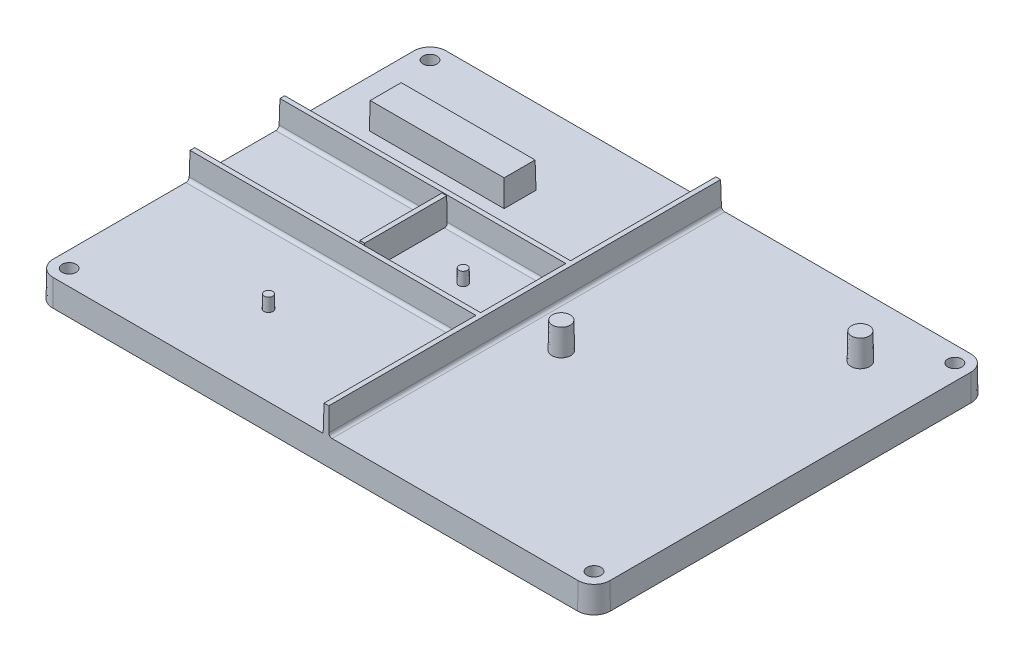
from build123d import *

# Parameters (mm, degrees)
SKETCH1_W            = 170
SKETCH1_H            = 120
BOSS_EXTRUDE1_DEPTH  = 8
SKETCH2_W            = 41.380626675
SKETCH2_H            = 10
BOSS_EXTRUDE2_DEPTH  = 8
SKETCH3_R            = 2
CUT_EXTRUDE1_DEPTH   = 8
SKETCH7_R            = 3
BOSS_EXTRUDE3_DEPTH  = 8
SKETCH8_R            = 1.5
BOSS_EXTRUDE6_DEPTH  = 4
SKETCH9_R            = 1.5
BOSS_EXTRUDE7_DEPTH  = 4
SKETCH10_R           = 3
BOSS_EXTRUDE8_DEPTH  = 8
SKETCH11_W           = 2
SKETCH11_H           = 120
BOSS_EXTRUDE9_DEPTH  = 8
SKETCH13_W           = 87.148503305
SKETCH13_H           = 2
BOSS_EXTRUDE10_DEPTH = 8
BOSS_EXTRUDE11_START = -1.289738394
SKETCH7_3_R          = 3
BOSS_EXTRUDE11_DEPTH = 1.289738394
SKETCH14_W           = 2
SKETCH14_H           = 25
BOSS_EXTRUDE13_DEPTH = 8
SKETCH18_W           = 87.148503305
SKETCH18_H           = 2
BOSS_EXTRUDE16_DEPTH = 8
SKETCH19_R           = 1.5
BOSS_EXTRUDE17_DEPTH = 4
DRAFT3_ANGLE         = 1
FILLET1_R            = 1
FILLET6_R            = 5
DRAFT1_ANGLE         = -1
DRAFT2_ANGLE         = 1
DRAFT4_ANGLE         = 1


with BuildPart() as part:
    # Sketch1 → Boss-Extrude1 (new body)
    with BuildSketch(Plane(origin=(0, 0, 0), x_dir=(1, 0, 0), z_dir=(0, 1, 0))):
        Rectangle(SKETCH1_W, SKETCH1_H)
    extrude(amount=BOSS_EXTRUDE1_DEPTH)

    # Sketch2 → Boss-Extrude2 (add)
    with BuildSketch(Plane(origin=(-17.791513114, 8, -3.068036611), x_dir=(1, 0, 0), z_dir=(0, 1, 0))):
        with Locations((-32.208486886, 28.840032215)):
            Rectangle(SKETCH2_W, SKETCH2_H)
    extrude(amount=BOSS_EXTRUDE2_DEPTH)

    # Sketch3 → Cut-Extrude1 (cut)
    with BuildSketch(Plane(origin=(0, 8, 0), x_dir=(1, 0, 0), z_dir=(0, 1, 0))):
        with Locations((-80, 55)):
            Circle(SKETCH3_R)
        with Locations((-80, -55)):
            Circle(SKETCH3_R)
        with Locations((80, 55)):
            Circle(SKETCH3_R)
        with Locations((80, -55)):
            Circle(SKETCH3_R)
    extrude(amount=-CUT_EXTRUDE1_DEPTH, mode=Mode.SUBTRACT)

    # Sketch7 → Boss-Extrude3 (add)
    with BuildSketch(Plane(origin=(12.703147983, 8, 3.565766466), x_dir=(1, 0, 0), z_dir=(0, 1, 0))):
        with Locations((52.400485428, 44.659504627)):
            Circle(SKETCH7_R)
    extrude(amount=BOSS_EXTRUDE3_DEPTH)

    # Sketch8 → Boss-Extrude6 (add)
    with BuildSketch(Plane(origin=(0, 16, 3.565766466), x_dir=(1, 0, 0), z_dir=(0, 1, 0))):
        with Locations((65.103633411, 44.659504627)):
            Circle(SKETCH8_R)
    extrude(amount=-BOSS_EXTRUDE6_DEPTH)

    # Sketch9 → Boss-Extrude7 (add)
    with BuildSketch(Plane(origin=(0, 16, 3.565766466), x_dir=(1, 0, 0), z_dir=(0, 1, 0))):
        with Locations((64.905146724, 44.273718651)):
            Circle(SKETCH9_R)
    extrude(amount=-BOSS_EXTRUDE7_DEPTH)

    # Sketch10 → Boss-Extrude8 (add)
    with BuildSketch(Plane(origin=(-8.754663217, 8, 20.46794397), x_dir=(1, 0, 0), z_dir=(0, 1, 0))):
        with Locations((25.406295965, 18.856235287)):
            Circle(SKETCH10_R)
    extrude(amount=BOSS_EXTRUDE8_DEPTH)

    # Sketch11 → Boss-Extrude9 (add)
    with BuildSketch(Plane(origin=(4.148503305, 8, 0), x_dir=(1, 0, 0), z_dir=(0, 1, 0))):
        with Locations((-1, 0)):
            Rectangle(SKETCH11_W, SKETCH11_H)
    extrude(amount=BOSS_EXTRUDE9_DEPTH)

    # Sketch13 → Boss-Extrude10 (add)
    with BuildSketch(Plane(origin=(0, 8, 0), x_dir=(1, 0, 0), z_dir=(0, 1, 0))):
        with Locations((-41.425748347, 14.695581419)):
            Rectangle(SKETCH13_W, SKETCH13_H)
    extrude(amount=BOSS_EXTRUDE10_DEPTH)

    # Sketch7_3 → Boss-Extrude11 (add)
    with BuildSketch(Plane(origin=(12.703147983, 8, 3.565766466), x_dir=(1, 0, 0), z_dir=(0, 1, 0)).offset(BOSS_EXTRUDE11_START)):
        with Locations((52.400485428, 44.659504627)):
            Circle(SKETCH7_3_R)
    extrude(amount=BOSS_EXTRUDE11_DEPTH)

    # Sketch18 → Boss-Extrude16 (add)
    with BuildSketch(Plane(origin=(0, 8, 0), x_dir=(1, 0, 0), z_dir=(0, 1, 0))):
        with Locations((-41.425748347, -12.710714547)):
            Rectangle(SKETCH18_W, SKETCH18_H)
    extrude(amount=BOSS_EXTRUDE16_DEPTH)

    # Sketch19 → Boss-Extrude17 (add)
    with BuildSketch(Plane(origin=(0, 8, 0), x_dir=(1, 0, 0), z_dir=(0, 1, 0))):
        with Locations((-16.06228854, 1.18486687)):
            Circle(SKETCH19_R)
        with Locations((-38.901806458, -35.330630327)):
            Circle(SKETCH19_R)
    extrude(amount=BOSS_EXTRUDE17_DEPTH)

    # Draft3
    draft3_faces = [part.faces().sort_by_distance(p)[0] for p in [
        (-17.56228854, 10, -1.18486687),
        (78, 4, -55),
        (-82, 4, -55),
        (78, 4, 55),
        (-82, 4, 55),
        (4.148503305, 12, 0),
        (-29.309686662, 12, -31.908068826),
        (-50, 12, -26.908068826),
        (-70.690313338, 12, -31.908068826),
        (-50, 12, -36.908068826),
        (-40.401806458, 10, 35.330630327),
        (13.651632748, 12, 1.611708683),
        (62.103633411, 12, -41.093738161),
        (-41.425748348, 12, -13.695581419),
        (-41.425748348, 12, -15.695581419),
        (-41.425748348, 12, 11.710714547),
        (-41.425748348, 12, 13.710714547),
        (2.148503305, 12, 36.855357273),
        (2.148503305, 12, -0.992433436),
        (2.148503305, 12, -37.847790709),
    ]]
    draft(draft3_faces, Plane.ZX, DRAFT3_ANGLE)

    # Fillet1
    fillet1_edges = [part.edges().sort_by_distance(p)[0] for p in [
        (-41.355928088, 8, 13.571074027),
        (-41.355928088, 8, 11.850355066),
        (-41.355928088, 8, -13.835221938),
        (2.288143824, 8, -0.992433436),
        (4.008862785, 8, 0),
        (2.288143824, 8, -37.77797045),
        (-41.355928088, 8, -15.555940899),
    ]]
    fillet(fillet1_edges, radius=FILLET1_R)

    # Fillet6
    fillet6_edges = [part.edges().sort_by_distance(p)[0] for p in [
        (85, 4, -60),
        (85, 4, 60),
        (-85, 4, 60),
        (-85, 4, -60),
    ]]
    fillet(fillet6_edges, radius=FILLET6_R)

    # Draft1
    draft1_faces = [part.faces().sort_by_distance(p)[0] for p in [
        (83.535533906, 4, 58.535533906),
        (85, 4, 0),
        (83.535533906, 4, -58.535533906),
        (0.031801749, 4.078447927, -60),
        (-83.535533906, 4, -58.535533906),
        (-83.535533906, 4, 58.535533906),
        (-85, 4.2238948, -0.028609533),
        (0.031476466, 4.077788114, 60),
    ]]
    draft(draft1_faces, Plane.ZX, DRAFT1_ANGLE)

    # Draft2
    draft2_faces = [part.faces().sort_by_distance(p)[0] for p in [
        (83.584904285, 4, -58.584904285),
        (85.06982026, 4, 0),
        (83.584904285, 4, 58.584904285),
        (0.031476466, 4.077788114, 60.071178056),
        (-83.584904285, 4, 58.584904285),
        (-85.073728358, 4.2238948, -0.028609533),
        (-83.584904285, 4, -58.584904285),
        (0.031801749, 4.078447927, -60.071189573),
    ]]
    draft(draft2_faces, Plane.ZX, DRAFT2_ANGLE)


with BuildPart() as body_2:
    # Sketch14 → Boss-Extrude13 (new body)
    with BuildSketch(Plane(origin=(0, 16, 0), x_dir=(1, 0, 0), z_dir=(0, 1, 0))):
        with Locations((-34.330630327, 1.195581419)):
            Rectangle(SKETCH14_W, SKETCH14_H)
    extrude(amount=-BOSS_EXTRUDE13_DEPTH)

    # Draft4
    draft4_faces = [body_2.faces().sort_by_distance(p)[0] for p in [
        (-35.330630327, 12, -1.195581419),
        (-33.330630327, 12, -1.195581419),
    ]]
    draft(draft4_faces, Plane.ZX, DRAFT4_ANGLE)


solid = Compound([part.part, body_2.part])
